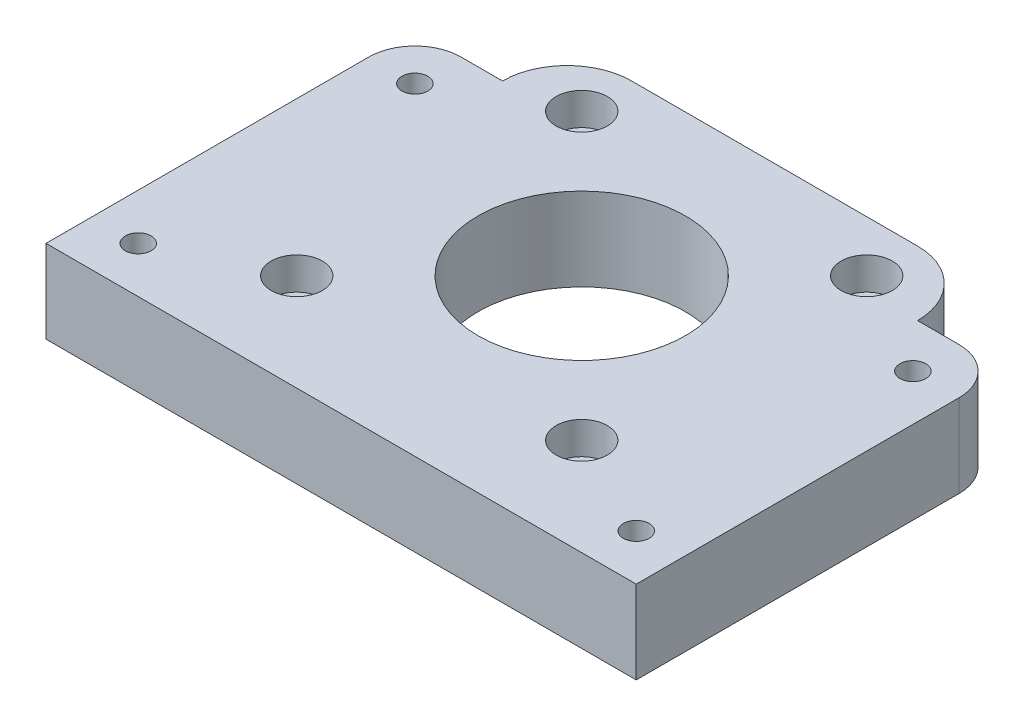
from build123d import *

# Parameters (mm, degrees)
BOSS_EXTRUDE1_DEPTH = 9
SKETCH2_R           = 11.25
CUT_EXTRUDE1_DEPTH  = 9
SKETCH3_R           = 2.775
CUT_EXTRUDE2_DEPTH  = 3.5
SKETCH5_R           = 2.775
CUT_EXTRUDE4_DEPTH  = 3.5
SKETCH4_R           = 1.5
CUT_EXTRUDE3_DEPTH  = 6
SKETCH6_R           = 1.4
CUT_EXTRUDE5_DEPTH  = 6


with BuildPart() as part:
    # Sketch1 → Boss-Extrude1 (new body)
    with BuildSketch(Plane(origin=(0, 0, 0), x_dir=(1, 0, 0), z_dir=(0, 1, 0))):
        with BuildLine():
            Line((-15.5, 29.5), (15.5, 29.5))
            ThreePointArc((15.5, 29.5), (20.449747468, 27.449747468), (22.5, 22.5))
            Line((22.5, 22.5), (27, 22.5))
            ThreePointArc((27, 22.5), (30.535533906, 21.035533906), (32, 17.5))
            Line((32, 17.5), (32, -17.5))
            Line((32, -17.5), (-32, -17.5))
            Line((-32, -17.5), (-32, 17.5))
            ThreePointArc((-32, 17.5), (-30.535533906, 21.035533906), (-27, 22.5))
            Line((-27, 22.5), (-22.5, 22.5))
            ThreePointArc((-22.5, 22.5), (-20.449747468, 27.449747468), (-15.5, 29.5))
        make_face()
    extrude(amount=BOSS_EXTRUDE1_DEPTH)

    # Sketch2 → Cut-Extrude1 (cut)
    with BuildSketch(Plane(origin=(0, 9, 0), x_dir=(1, 0, 0), z_dir=(0, 1, 0))):
        with Locations((0.09, 8.5)):
            Circle(SKETCH2_R)
    extrude(amount=-CUT_EXTRUDE1_DEPTH, mode=Mode.SUBTRACT)

    # Sketch3 → Cut-Extrude2 (cut)
    with BuildSketch(Plane(origin=(0, 9, 0), x_dir=(1, 0, 0), z_dir=(0, 1, 0))):
        with Locations((-15.360283169, 23.950283169)):
            Circle(SKETCH3_R)
        with Locations((15.540283169, 23.950283169)):
            Circle(SKETCH3_R)
        with Locations((15.540283169, -6.950283169)):
            Circle(SKETCH3_R)
        with Locations((-15.360283169, -6.950283169)):
            Circle(SKETCH3_R)
    extrude(amount=-CUT_EXTRUDE2_DEPTH, mode=Mode.SUBTRACT)

    # Sketch5 → Cut-Extrude4 (cut)
    with BuildSketch(Plane(origin=(0, 0, 0), x_dir=(1, 0, 0), z_dir=(0, 1, 0))):
        with Locations((-27, 17.5)):
            Circle(SKETCH5_R)
        with Locations((27, 17.5)):
            Circle(SKETCH5_R)
        with Locations((27, -12.5)):
            Circle(SKETCH5_R)
        with Locations((-27, -12.5)):
            Circle(SKETCH5_R)
    extrude(amount=CUT_EXTRUDE4_DEPTH, mode=Mode.SUBTRACT)

    # Sketch4 → Cut-Extrude3 (cut)
    with BuildSketch(Plane(origin=(0, 5.5, 0), x_dir=(1, 0, 0), z_dir=(0, 1, 0))):
        with Locations((-15.360283169, 23.950283169)):
            Circle(SKETCH4_R)
        with Locations((15.540283169, 23.950283169)):
            Circle(SKETCH4_R)
        with Locations((15.540283169, -6.950283169)):
            Circle(SKETCH4_R)
        with Locations((-15.360283169, -6.950283169)):
            Circle(SKETCH4_R)
    extrude(amount=-CUT_EXTRUDE3_DEPTH, mode=Mode.SUBTRACT)

    # Sketch6 → Cut-Extrude5 (cut)
    with BuildSketch(Plane(origin=(0, 3.5, 0), x_dir=(-1, 0, 0), z_dir=(0, -1, 0))):
        with Locations((-27, -12.5)):
            Circle(SKETCH6_R)
        with Locations((-27, 17.5)):
            Circle(SKETCH6_R)
        with Locations((27, 17.5)):
            Circle(SKETCH6_R)
        with Locations((27, -12.5)):
            Circle(SKETCH6_R)
    extrude(amount=-CUT_EXTRUDE5_DEPTH, mode=Mode.SUBTRACT)


solid = part.part
